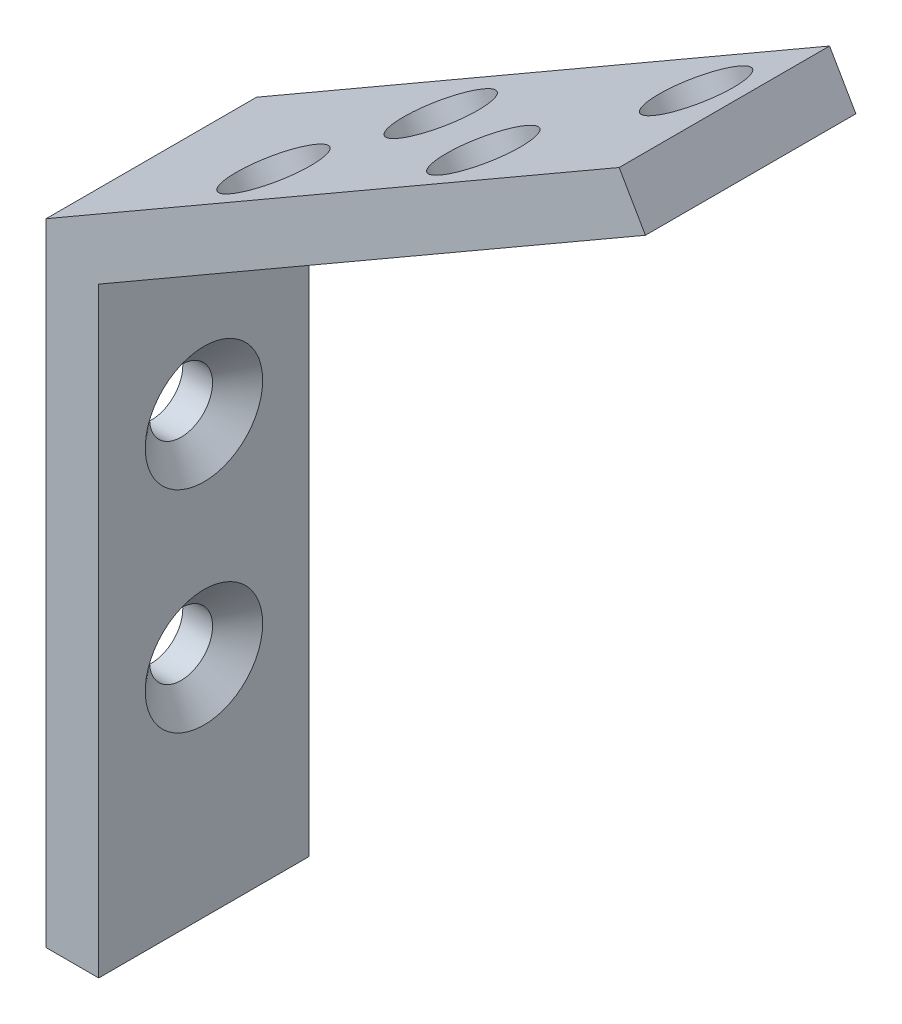
from build123d import *

# Parameters (mm, degrees)
BOSS_EXTRUDE1_DEPTH                               = 12.7
CSK_FOR_6_FLAT_HEAD_MACHINE_SCREW_100_D           = 3.7973
CSK_FOR_6_FLAT_HEAD_MACHINE_SCREW_100_DEPTH       = 12.7
CSK_FOR_6_FLAT_HEAD_MACHINE_SCREW_100_CSINK_D     = 7.0866
CSK_FOR_6_FLAT_HEAD_MACHINE_SCREW_100_CSINK_ANGLE = 100
CSK_FOR_6_FLAT_HEAD_MACHINE_SCREW_100_TIP         = 1.140824014
F_6_0_204_DIAMETER_HOLE1_D                        = 5.1816
F_6_0_204_DIAMETER_HOLE1_DEPTH                    = 12.7
F_6_0_204_DIAMETER_HOLE1_TIP                      = 1.556709692


with BuildPart() as part:
    # Sketch1 → Boss-Extrude1 (new body)
    with BuildSketch(Plane.XY):
        Polygon((-1.5875, 19.05), (32.995567884, 39.016543552), (34.583067884, 36.266912895), (1.5875, 17.216912895), (1.5875, -19.05), (-1.5875, -19.05), align=None)
    extrude(amount=BOSS_EXTRUDE1_DEPTH)

    # CSK for #6 Flat Head Machine Screw (100)1
    with Locations(Plane(origin=(1.5875, 0, 0), x_dir=(0, 0, -1), z_dir=(1, 0, 0))):
        with Locations((-6.35, 7.247907124), (-6.35, -5.463667213)):
            CounterSinkHole(CSK_FOR_6_FLAT_HEAD_MACHINE_SCREW_100_D / 2, CSK_FOR_6_FLAT_HEAD_MACHINE_SCREW_100_CSINK_D / 2, depth=CSK_FOR_6_FLAT_HEAD_MACHINE_SCREW_100_DEPTH, counter_sink_angle=CSK_FOR_6_FLAT_HEAD_MACHINE_SCREW_100_CSINK_ANGLE)
            with Locations((0, 0, -(CSK_FOR_6_FLAT_HEAD_MACHINE_SCREW_100_DEPTH + CSK_FOR_6_FLAT_HEAD_MACHINE_SCREW_100_TIP / 2))):  # 118° drill point
                Cone(0, CSK_FOR_6_FLAT_HEAD_MACHINE_SCREW_100_D / 2, CSK_FOR_6_FLAT_HEAD_MACHINE_SCREW_100_TIP, mode=Mode.SUBTRACT)

    # #6 (0.204) Diameter Hole1
    with Locations(Plane(origin=(-7.058266971, 12.225277007, 0), x_dir=(-0.866025404, -0.5, 0), z_dir=(0.5, -0.866025404, 0))):
        with Locations((-43.476510232, -4.066670618), (-34.423038878, -9.068831988), (-25.680281164, -4.066670618), (-19.798832438, -9.068831988)):
            Hole(F_6_0_204_DIAMETER_HOLE1_D / 2, depth=F_6_0_204_DIAMETER_HOLE1_DEPTH)
            with Locations((0, 0, -(F_6_0_204_DIAMETER_HOLE1_DEPTH + F_6_0_204_DIAMETER_HOLE1_TIP / 2))):  # 118° drill point
                Cone(0, F_6_0_204_DIAMETER_HOLE1_D / 2, F_6_0_204_DIAMETER_HOLE1_TIP, mode=Mode.SUBTRACT)


solid = part.part
